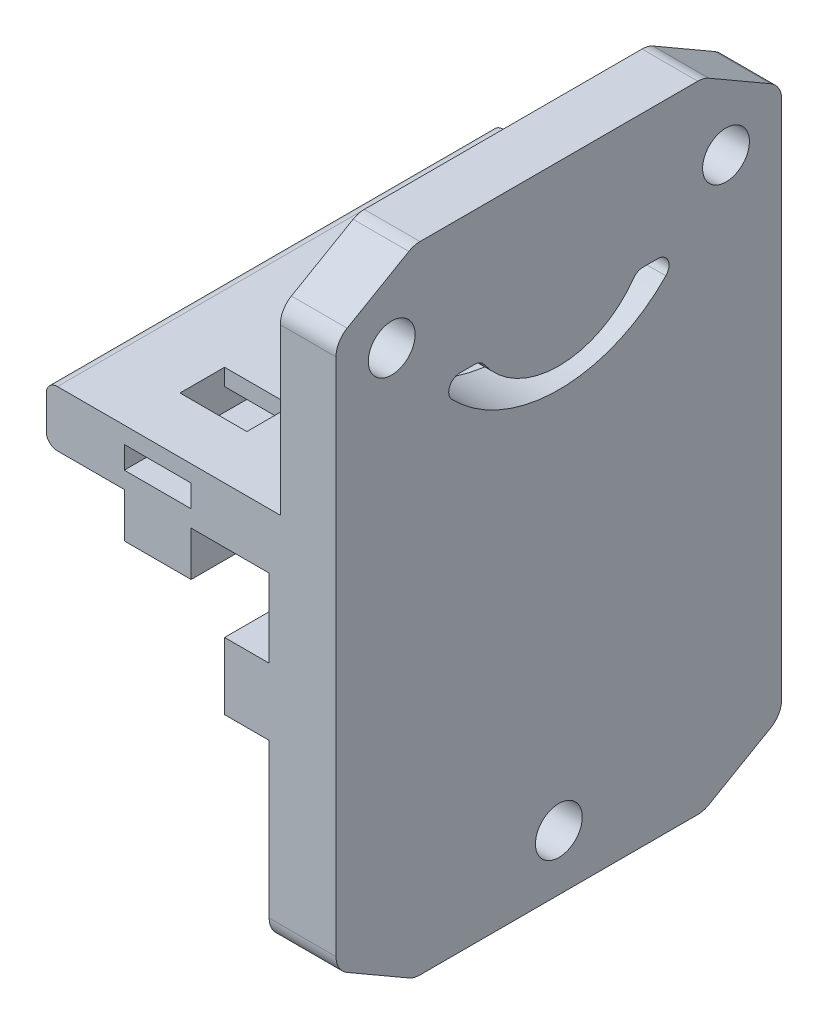
from build123d import *

# Parameters (mm, degrees)
ESQUISSE1_W              = 26
ESQUISSE1_H              = 50
BOSS_EXTRU_1_DEPTH       = 40
ESQUISSE2_W              = 20
ESQUISSE2_H              = 20
ENL_V_MAT_EXTRU_1_DEPTH  = 41
ESQUISSE3_W              = 6
ESQUISSE3_H              = 4
ESQUISSE3_W_2            = 4
ESQUISSE3_H_2            = 6
BOSS_EXTRU_2_DEPTH       = 40
ESQUISSE7_W              = 21
ESQUISSE7_H              = 20
ENL_V_MAT_EXTRU_4_DEPTH  = 41
ESQUISSE8_W              = 6
ESQUISSE8_H              = 2
ENL_V_MAT_EXTRU_5_DEPTH  = 41
ESQUISSE9_W              = 6
ESQUISSE9_H              = 4
ENL_V_MAT_EXTRU_6_DEPTH  = 3.5
ESQUISSE10_R             = 2.1
ENL_V_MAT_EXTRU_7_DEPTH  = 27
ENL_V_MAT_EXTRU_9_DEPTH  = 6
ESQUISSE13_W             = 26
ESQUISSE13_H             = 5
ENL_V_MAT_EXTRU_10_DEPTH = 41
CONG_1_R                 = 1
CONG_2_R                 = 1
ESQUISSE14_W             = 6
ESQUISSE14_H             = 40
BOSS_EXTRU_3_DEPTH       = 12
CHANFREIN1_SIZE          = 7
CHANFREIN1_SIZE2         = 4.041451884
CHANFREIN1_PART_2_SIZE   = 7
CHANFREIN1_PART_2_SIZE2  = 4.041451884
CONG_3_R                 = 2
ESQUISSE16_R             = 2.1
ENL_V_MAT_EXTRU_11_DEPTH = 27


with BuildPart() as part:
    # Esquisse1 → Boss.-Extru.1 (new body)
    with BuildSketch(Plane.XY):
        Rectangle(ESQUISSE1_W, ESQUISSE1_H)
    extrude(amount=BOSS_EXTRU_1_DEPTH)

    # Esquisse2 → Enlèv. mat.-Extru.1 (cut, through all)
    with BuildSketch(Plane.XY.offset(40)):
        with Locations((-3, -10)):
            Rectangle(ESQUISSE2_W, ESQUISSE2_H)
    extrude(amount=-ENL_V_MAT_EXTRU_1_DEPTH, mode=Mode.SUBTRACT)

    # Esquisse3 → Boss.-Extru.2 (add)
    with BuildSketch(Plane.XY.offset(40)):
        with Locations((-3, -2)):
            Rectangle(ESQUISSE3_W, ESQUISSE3_H)
        with Locations((5, -10)):
            Rectangle(ESQUISSE3_W_2, ESQUISSE3_H_2)
    extrude(amount=-BOSS_EXTRU_2_DEPTH)

    # Esquisse7 → Enlèv. mat.-Extru.4 (cut, through all)
    with BuildSketch(Plane.XY.offset(40)):
        with Locations((-2.5, 15)):
            Rectangle(ESQUISSE7_W, ESQUISSE7_H)
    extrude(amount=-ENL_V_MAT_EXTRU_4_DEPTH, mode=Mode.SUBTRACT)

    # Esquisse8 → Enlèv. mat.-Extru.5 (cut, through all)
    with BuildSketch(Plane.XY.offset(40)):
        with Locations((-3, 2.5)):
            Rectangle(ESQUISSE8_W, ESQUISSE8_H)
    extrude(amount=-ENL_V_MAT_EXTRU_5_DEPTH, mode=Mode.SUBTRACT)

    # Esquisse9 → Enlèv. mat.-Extru.6 (cut)
    with BuildSketch(Plane(origin=(0, 5, 0), x_dir=(1, 0, 0), z_dir=(0, 1, 0))):
        with Locations((-3, -33)):
            Rectangle(ESQUISSE9_W, ESQUISSE9_H)
        with Locations((-3, -7)):
            Rectangle(ESQUISSE9_W, ESQUISSE9_H)
    extrude(amount=-ENL_V_MAT_EXTRU_6_DEPTH, mode=Mode.SUBTRACT)

    # Esquisse10 → Enlèv. mat.-Extru.7 (cut, through all)
    with BuildSketch(Plane(origin=(13, 0, 0), x_dir=(0, 0, -1), z_dir=(1, 0, 0))):
        with Locations((-35, 18)):
            Circle(ESQUISSE10_R)
        with Locations((-5, 18)):
            Circle(ESQUISSE10_R)
    extrude(amount=-ENL_V_MAT_EXTRU_7_DEPTH, mode=Mode.SUBTRACT)

    # Esquisse12 → Enlèv. mat.-Extru.9 (cut, through all)
    with BuildSketch(Plane.ZY.offset(-8)):
        with BuildLine():
            Line((9, 13), (13, 13))
            ThreePointArc((13, 13), (20, 9.097518313), (27, 13))
            Line((27, 13), (31, 13))
            ThreePointArc((31, 13), (20, 7.247854519), (9, 13))
        make_face()
    extrude(amount=-ENL_V_MAT_EXTRU_9_DEPTH, mode=Mode.SUBTRACT)

    # Esquisse13 → Enlèv. mat.-Extru.10 (cut, through all)
    with BuildSketch(Plane(origin=(0, 0, 0), x_dir=(-1, 0, 0), z_dir=(0, 0, -1))):
        with Locations((0, -22.5)):
            Rectangle(ESQUISSE13_W, ESQUISSE13_H)
    extrude(amount=-ENL_V_MAT_EXTRU_10_DEPTH, mode=Mode.SUBTRACT)

    # Congé1
    cong_1_edges = [part.edges().sort_by_distance(p)[0] for p in [
        (-13, 0, 20),
        (-13, 5, 20),
    ]]
    fillet(cong_1_edges, radius=CONG_1_R)

    # Congé2
    cong_2_edges = [part.edges().sort_by_distance(p)[0] for p in [
        (10.5, 13, 31),
        (10.5, 13, 9),
        (10.5, 13, 13),
        (10.5, 13, 27),
    ]]
    fillet(cong_2_edges, radius=CONG_2_R)

    # Esquisse14 → Boss.-Extru.3 (add)
    with BuildSketch(Plane.XZ.offset(20)):
        with Locations((10, 20)):
            Rectangle(ESQUISSE14_W, ESQUISSE14_H)
    extrude(amount=BOSS_EXTRU_3_DEPTH)

    # Chanfrein1
    chanfrein1_edges = [part.edges().sort_by_distance(p)[0] for p in [
        (10.5, 25, 40),
        (10.5, 25, 0),
    ]]
    chanfrein1_side = [part.faces().sort_by_distance(p)[0] for p in [
        (10.5, 25, 20),
    ]]
    chamfer(chanfrein1_edges, length=CHANFREIN1_SIZE, length2=CHANFREIN1_SIZE2, reference=chanfrein1_side[0])

    # Chanfrein1 part 2
    chanfrein1_part_2_edges = [part.edges().sort_by_distance(p)[0] for p in [
        (10, -32, 40),
        (10, -32, 0),
    ]]
    chanfrein1_part_2_side = [part.faces().sort_by_distance(p)[0] for p in [
        (10, -32, 20),
    ]]
    chamfer(chanfrein1_part_2_edges, length=CHANFREIN1_PART_2_SIZE, length2=CHANFREIN1_PART_2_SIZE2, reference=chanfrein1_part_2_side[0])

    # Congé3
    cong_3_edges = [part.edges().sort_by_distance(p)[0] for p in [
        (10, -32, 7),
        (10, -32, 33),
        (10.5, 20.958548116, 40),
        (10, -27.958548116, 40),
        (10.5, 20.958548116, 0),
        (10, -27.958548116, 0),
        (10.5, 25, 7),
        (10.5, 25, 33),
    ]]
    fillet(cong_3_edges, radius=CONG_3_R)

    # Esquisse16 → Enlèv. mat.-Extru.11 (cut, through all)
    with BuildSketch(Plane(origin=(13, 0, 0), x_dir=(0, 0, -1), z_dir=(1, 0, 0))):
        with Locations((-20, -27)):
            Circle(ESQUISSE16_R)
    extrude(amount=-ENL_V_MAT_EXTRU_11_DEPTH, mode=Mode.SUBTRACT)


solid = part.part
